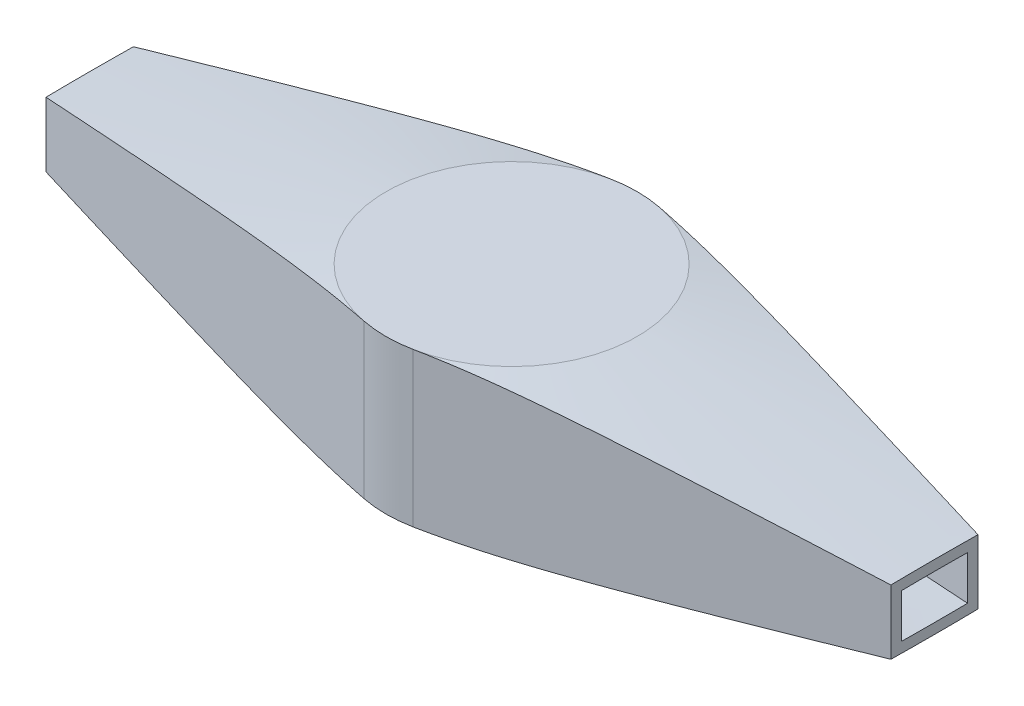
from build123d import *

# Parameters (mm, degrees)
SKETCH_1_R               = 49
EXTRUDE_1_DEPTH          = 30
SKETCH_16_R              = 250
SKETCH_16_5_R            = 250
SKETCH_14_OUTSIDE_W      = 643.93
SKETCH_14_OUTSIDE_H      = 643.93
CUT_EXTRUDE_1_DEPTH      = 355.823900134
CUT_EXTRUDE_1_DEPTH_BACK = 355.823900134
SHELL_1_T                = 4
SKETCH_15_OUTSIDE_W      = 604.606
SKETCH_15_OUTSIDE_H      = 202.606
CUT_EXTRUDE_2_DEPTH      = 257.517055963
CUT_EXTRUDE_2_DEPTH_BACK = 257.517055963


with BuildPart() as part:
    # 草图1 → 凸台-拉伸1 (new, symmetric)
    with BuildSketch(Plane(origin=(0, 0, 0), x_dir=(1, 0, 0), z_dir=(0, 1, 0))):
        with Locations(Location((0, 0, 0), (0, 0, 270))):
            Circle(SKETCH_1_R)
    extrude(amount=EXTRUDE_1_DEPTH, both=True)

    # 草图16 → section 0 of loft_1
    with BuildSketch(Plane(origin=(0, 0, 0), x_dir=(1, 0, 0), z_dir=(0, 1, 0)), mode=Mode.PRIVATE) as loft_1_s0:
        Circle(SKETCH_16_R)
    # loft up to a face of the part (loft_1)
    loft([loft_1_s0.sketch, Face(Wire([part.edges().sort_by_distance((35.719462744, 30, -33.542808191))[0]]))])

    # 草图16<5> → section 0 of loft_3
    with BuildSketch(Plane(origin=(0, 0, 0), x_dir=(1, 0, 0), z_dir=(0, 1, 0)), mode=Mode.PRIVATE) as loft_3_s0:
        Circle(SKETCH_16_5_R)
    # loft up to a face of the part (loft_3)
    loft([loft_3_s0.sketch, Face(Wire([part.edges().sort_by_distance((-35.719462744, -30, -33.542808191))[0]]))])

    # 草图14 outside → 切除-拉伸1 (cut, two sides)
    with BuildSketch(Plane(origin=(0, 0, 0), x_dir=(1, 0, 0), z_dir=(0, 1, 0))) as cut_extrude_1_sk:
        Rectangle(SKETCH_14_OUTSIDE_W, SKETCH_14_OUTSIDE_H)
        with BuildLine():
            Line((-250, 0), (-9.604, -48.049590883))
            ThreePointArc((-9.604, -48.049590883), (0, -49), (9.604, -48.049590883))
            Line((9.604, -48.049590883), (250, 0))
            Line((250, 0), (9.604, 48.049590883))
            ThreePointArc((9.604, 48.049590883), (1.6e-08, 49), (-9.603999968, 48.049590889))
            Line((-9.603999968, 48.049590889), (-250, 0))
        make_face(mode=Mode.SUBTRACT)
    extrude(amount=CUT_EXTRUDE_1_DEPTH, mode=Mode.SUBTRACT)
    extrude(cut_extrude_1_sk.sketch, amount=-CUT_EXTRUDE_1_DEPTH_BACK, mode=Mode.SUBTRACT)

    # 抽壳1 (no face opened: a closed hollow body)
    add(offset(amount=-SHELL_1_T, mode=Mode.PRIVATE), mode=Mode.SUBTRACT)

    # 草图15 outside → 切除-拉伸2 (cut, two sides)
    with BuildSketch(Plane(origin=(0, 0, 0), x_dir=(1, 0, 0), z_dir=(0, 1, 0))) as cut_extrude_2_sk:
        Rectangle(SKETCH_15_OUTSIDE_W, SKETCH_15_OUTSIDE_H)
        with BuildLine():
            Line((-9.60400022, -48.049590839), (-164.621347882, -17.065214498))
            Line((-164.621347882, -17.065214498), (-164.621347882, 17.065214498))
            Line((-164.621347882, 17.065214498), (-9.604, 48.049590883))
            ThreePointArc((-9.604, 48.049590883), (0, 49), (9.604, 48.049590883))
            Line((9.604, 48.049590883), (165, 16.989530712))
            Line((165, 16.989530712), (165, -16.989530712))
            Line((165, -16.989530712), (9.604, -48.049590883))
            ThreePointArc((9.604, -48.049590883), (-1.12e-07, -49), (-9.60400022, -48.049590839))
        make_face(mode=Mode.SUBTRACT)
    extrude(amount=CUT_EXTRUDE_2_DEPTH, mode=Mode.SUBTRACT)
    extrude(cut_extrude_2_sk.sketch, amount=-CUT_EXTRUDE_2_DEPTH_BACK, mode=Mode.SUBTRACT)


solid = part.part
